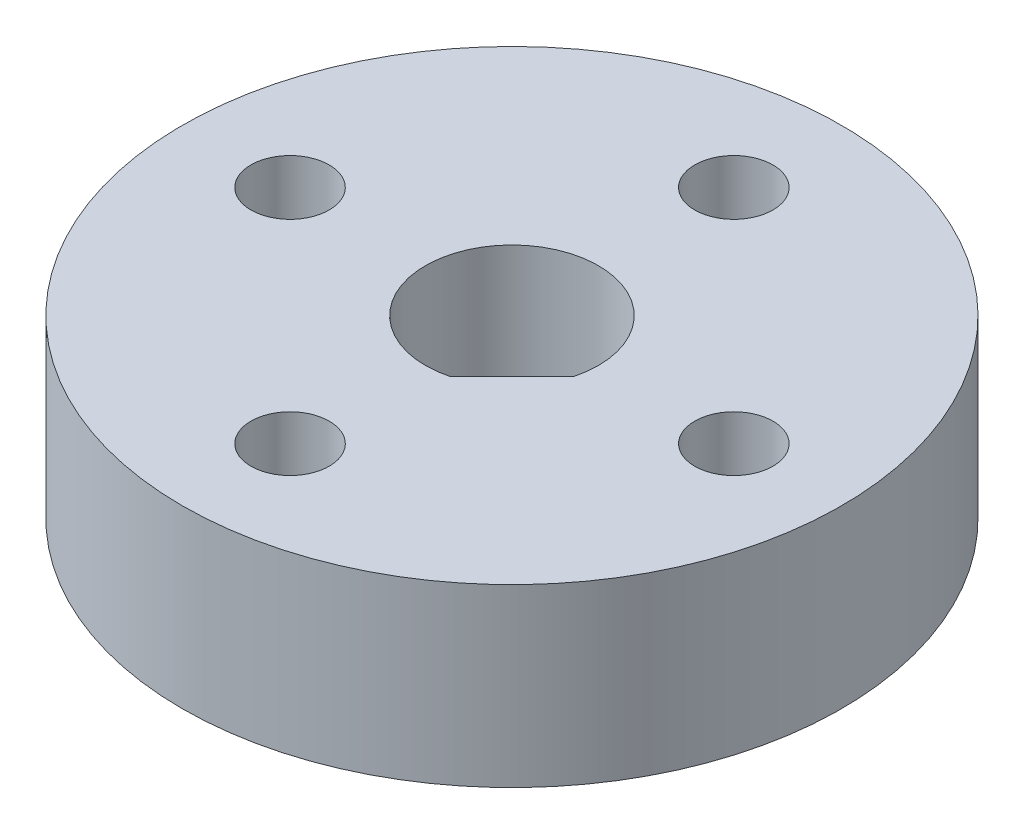
from build123d import *

# Parameters (mm, degrees)
SKETCH1_R                   = 9.525
BOSS_EXTRUDE1_DEPTH         = 5.08
F_43_0_089_DIAMETER_HOLE1_D = 2.2606
CIRPATTERN1_COUNT           = 4


with BuildPart() as part:
    # Sketch1 → Boss-Extrude1 (new body)
    with BuildSketch(Plane(origin=(0, 0, 0), x_dir=(1, 0, 0), z_dir=(0, 1, 0))):
        Circle(SKETCH1_R)
        with BuildLine():
            Line((0.624652949, -2.420704173), (2.420704173, -0.624652949))
            ThreePointArc((2.420704173, -0.624652949), (-1.767766953, 1.767766953), (0.624652949, -2.420704173))
        make_face(mode=Mode.SUBTRACT)
    extrude(amount=BOSS_EXTRUDE1_DEPTH)

    # #43 (0.089) Diameter Hole1 (through all)
    with Locations(Plane(origin=(0, 5.08, 0), x_dir=(1, 0, 0), z_dir=(0, 1, 0))):
        with Locations((0, 6.413072646)):
            f_43_0_089_diameter_hole1 = Hole(F_43_0_089_DIAMETER_HOLE1_D / 2)

    # CirPattern1: #43 (0.089) Diameter Hole1 ×4 about axis
    cirpattern1_axis = Axis((0, 0, 0), (0, 1, 0))
    for i in range(1, CIRPATTERN1_COUNT):
        add(f_43_0_089_diameter_hole1.rotate(cirpattern1_axis, i * 360 / CIRPATTERN1_COUNT), mode=Mode.SUBTRACT)


solid = part.part
